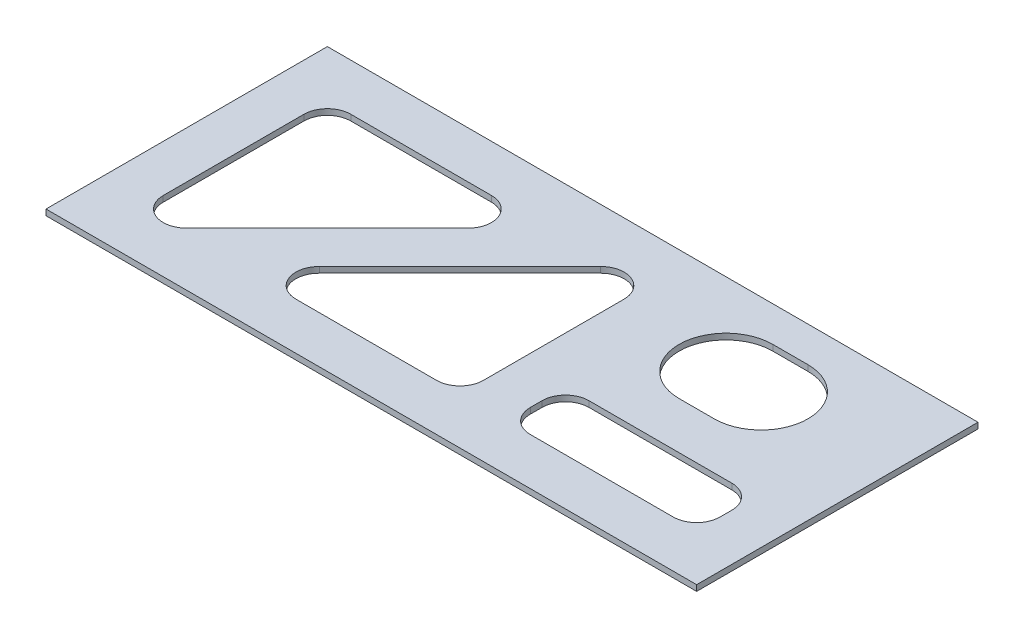
from build123d import *

# Parameters (mm, degrees)
SKETCH1_W           = 352.425
SKETCH1_H           = 152.4
BOSS_EXTRUDE1_DEPTH = 1.5875
CUT_EXTRUDE1_DEPTH  = 4.175


with BuildPart() as part:
    # Sketch1 → Boss-Extrude1 (new body, symmetric)
    with BuildSketch(Plane(origin=(0, 0, 0), x_dir=(1, 0, 0), z_dir=(0, 1, 0))):
        Rectangle(SKETCH1_W, SKETCH1_H)
    extrude(amount=BOSS_EXTRUDE1_DEPTH, both=True)

    # Sketch2 → Cut-Extrude1 (cut, through all)
    with BuildSketch(Plane(origin=(0, 1.5875, 0), x_dir=(1, 0, 0), z_dir=(0, 1, 0))):
        with BuildLine():
            Line((103.1875, 6.35), (84.1375, 6.35))
            ThreePointArc((84.1375, 6.35), (58.7375, 31.75), (84.1375, 57.15))
            Line((84.1375, 57.15), (103.1875, 57.15))
            ThreePointArc((103.1875, 57.15), (128.5875, 31.75), (103.1875, 6.35))
        make_face()
        with BuildLine():
            Line((-138.1125, 50.8), (-61.9125, 50.8))
            ThreePointArc((-61.9125, 50.8), (-50.179229937, 42.960079591), (-52.932243879, 29.119743879))
            Line((-52.932243879, 29.119743879), (-129.132243879, -47.080256121))
            ThreePointArc((-129.132243879, -47.080256121), (-142.972579591, -49.833270063), (-150.8125, -38.1))
            Line((-150.8125, -38.1), (-150.8125, 38.1))
            ThreePointArc((-150.8125, 38.1), (-147.092756121, 47.080256121), (-138.1125, 50.8))
        make_face()
        with BuildLine():
            Line((-66.270451031, -50.8), (9.929548969, -50.8))
            ThreePointArc((9.929548969, -50.8), (18.90980509, -47.080256121), (22.629548969, -38.1))
            Line((22.629548969, -38.1), (22.629548969, 38.1))
            ThreePointArc((22.629548969, 38.1), (14.78962856, 49.833270063), (0.949292847, 47.080256121))
            Line((0.949292847, 47.080256121), (-75.250707153, -29.119743879))
            ThreePointArc((-75.250707153, -29.119743879), (-78.003721094, -42.960079591), (-66.270451031, -50.8))
        make_face()
        with BuildLine():
            Line((60.729548969, -50.8), (138.1125, -50.8))
            ThreePointArc((138.1125, -50.8), (147.092756121, -47.080256121), (150.8125, -38.1))
            Line((150.8125, -38.1), (150.8125, -31.75))
            ThreePointArc((150.8125, -31.75), (147.092756121, -22.769743879), (138.1125, -19.05))
            Line((138.1125, -19.05), (60.729548969, -19.05))
            ThreePointArc((60.729548969, -19.05), (51.749292847, -22.769743879), (48.029548969, -31.75))
            Line((48.029548969, -31.75), (48.029548969, -38.1))
            ThreePointArc((48.029548969, -38.1), (51.749292847, -47.080256121), (60.729548969, -50.8))
        make_face()
    extrude(amount=-CUT_EXTRUDE1_DEPTH, mode=Mode.SUBTRACT)


solid = part.part
